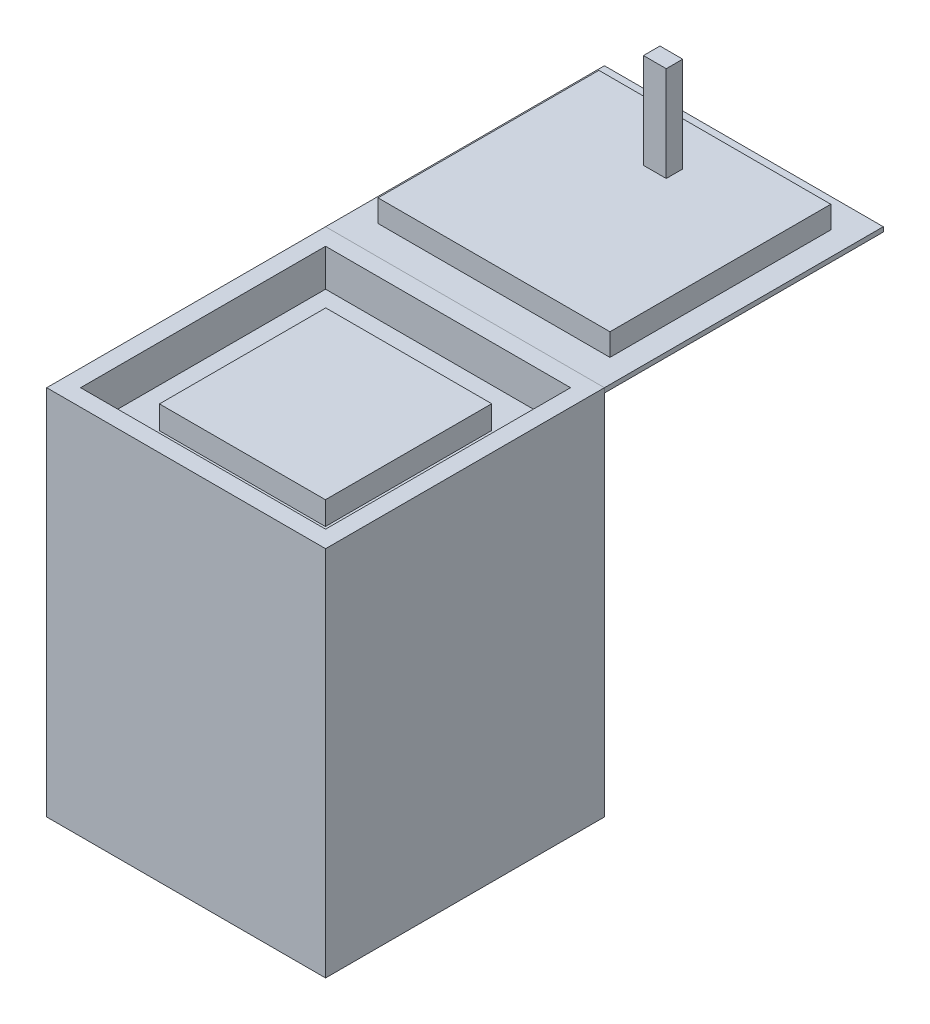
from build123d import *

# Parameters (mm, degrees)
SKETCH1_W           = 600
SKETCH1_H           = 600
BOSS_EXTRUDE1_DEPTH = 800
SKETCH2_W           = 527.145840922
SKETCH2_H           = 527.145840922
CUT_EXTRUDE2_DEPTH  = 80
SKETCH3_W           = 357.119076562
SKETCH3_H           = 357.823453438
BOSS_EXTRUDE2_DEPTH = 50
SKETCH4_W           = 600
SKETCH4_H           = 600
BOSS_EXTRUDE3_DEPTH = 10
SKETCH7_W           = 475.188659882
SKETCH7_H           = 47.834663464
BOSS_EXTRUDE8_DEPTH = 249.5
SKETCH15_W          = 35.508173295
SKETCH15_H          = 204.665336536
BOSS_EXTRUDE9_DEPTH = 24.5


with BuildPart() as part:
    # Sketch1 → Boss-Extrude1 (new body)
    with BuildSketch(Plane(origin=(0, 0, 0), x_dir=(1, 0, 0), z_dir=(0, 1, 0))):
        Rectangle(SKETCH1_W, SKETCH1_H)
    extrude(amount=BOSS_EXTRUDE1_DEPTH)

    # Sketch2 → Cut-Extrude2 (cut)
    with BuildSketch(Plane(origin=(0, 800, 0), x_dir=(1, 0, 0), z_dir=(0, 1, 0))):
        Rectangle(SKETCH2_W, SKETCH2_H)
    extrude(amount=-CUT_EXTRUDE2_DEPTH, mode=Mode.SUBTRACT)

    # Sketch3 → Boss-Extrude2 (add)
    with BuildSketch(Plane(origin=(0, 720, 0), x_dir=(1, 0, 0), z_dir=(0, 1, 0))):
        Rectangle(SKETCH3_W, SKETCH3_H)
    extrude(amount=BOSS_EXTRUDE2_DEPTH)


with BuildPart() as body_2:
    # Sketch4 → Boss-Extrude3 (new body)
    with BuildSketch(Plane(origin=(0, 800, 0), x_dir=(1, 0, 0), z_dir=(0, 1, 0))):
        with Locations((0, 600)):
            Rectangle(SKETCH4_W, SKETCH4_H)
    extrude(amount=-BOSS_EXTRUDE3_DEPTH)


with BuildPart() as body_3:
    # Sketch7 → Boss-Extrude8 (new body, symmetric)
    with BuildSketch(Plane(origin=(0, 0, 0), x_dir=(0, 0, -1), z_dir=(1, 0, 0))):
        with Locations((600, 823.917331732)):
            Rectangle(SKETCH7_W, SKETCH7_H)
    extrude(amount=BOSS_EXTRUDE8_DEPTH, both=True)

    # Sketch15 → Boss-Extrude9 (add, symmetric)
    with BuildSketch(Plane(origin=(0, 0, 0), x_dir=(0, 0, -1), z_dir=(1, 0, 0))):
        with Locations((726.23170897, 950.167331732)):
            Rectangle(SKETCH15_W, SKETCH15_H)
    extrude(amount=BOSS_EXTRUDE9_DEPTH, both=True)


solid = Compound([part.part, body_2.part, body_3.part])
